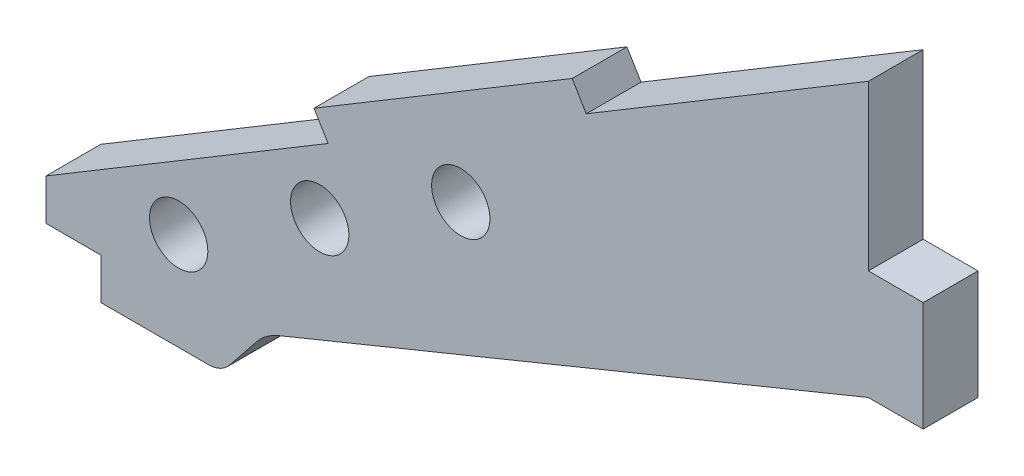
from build123d import *

# Parameters (mm, degrees)
BOSS_EXTRUDE1_DEPTH     = 6.35
CUT_EXTRUDE2_DEPTH      = 7.35
FILLET2_R               = 6.35
SKETCH4_W               = 6.35
SKETCH4_H               = 12.7
SKETCH4_H_2             = 4.7625
BOSS_EXTRUDE2_DEPTH     = 6.35
SKETCH5_W               = 13.97
SKETCH5_H               = 9.525
CUT_EXTRUDE3_DEPTH      = 7.35
FILLET3_R               = 3.175
F_1_4_CLEARANCE_HOLE1_D = 6.7564
BOSS_EXTRUDE3_DEPTH     = 6.35


with BuildPart() as part:
    # Sketch1 → Boss-Extrude1 (new body)
    with BuildSketch(Plane.XY):
        Polygon((-82.55, -19.05), (0, 0), (-88.9, 0), (-88.9, -19.05), align=None)
        Polygon((-95.25, 0), (0, 57.118902343), (0, 0), align=None)
    extrude(amount=BOSS_EXTRUDE1_DEPTH)

    # Sketch3 → Cut-Extrude2 (cut, through all)
    with BuildSketch(Plane.XY.offset(6.35)):
        Polygon((-82.55, -19.05), (-69.85, -3.175), (0, 25.4), (0, 0), align=None)
    extrude(amount=-CUT_EXTRUDE2_DEPTH, mode=Mode.SUBTRACT)

    # Fillet2
    fillet2_edges = [part.edges().sort_by_distance(p)[0] for p in [
        (-69.85, -3.175, 3.175),
    ]]
    fillet(fillet2_edges, radius=FILLET2_R)

    # Sketch4 → Boss-Extrude2 (add)
    with BuildSketch(Plane.XY.offset(6.35)):
        with Locations((3.175, 31.75)):
            Rectangle(SKETCH4_W, SKETCH4_H)
        with Locations((-92.075, -2.38125)):
            Rectangle(SKETCH4_W, SKETCH4_H_2)
    extrude(amount=-BOSS_EXTRUDE2_DEPTH)

    # Sketch5 → Cut-Extrude3 (cut, through all)
    with BuildSketch(Plane.XY.offset(6.35)):
        with Locations((-81.915, -14.2875)):
            Rectangle(SKETCH5_W, SKETCH5_H)
    extrude(amount=-CUT_EXTRUDE3_DEPTH, mode=Mode.SUBTRACT)

    # Fillet3
    fillet3_edges = [part.edges().sort_by_distance(p)[0] for p in [
        (-74.93, -9.525, 3.175),
    ]]
    fillet(fillet3_edges, radius=FILLET3_R)

    # 1/4 Clearance Hole1 (through all)
    with Locations(Plane.XY.offset(6.35)):
        with Locations((-79.884098694, 1.810281574), (-63.546505707, 11.607503394), (-47.20891272, 21.404725214)):
            Hole(F_1_4_CLEARANCE_HOLE1_D / 2)

    # Sketch8 → Boss-Extrude3 (add)
    with BuildSketch(Plane.XY.offset(6.35)):
        Polygon((-32.675185974, 37.524458703), (-34.308056278, 40.247390867), (-64.207684329, 22.317375804), (-62.574814026, 19.59444364), align=None)
    extrude(amount=-BOSS_EXTRUDE3_DEPTH)


solid = part.part
